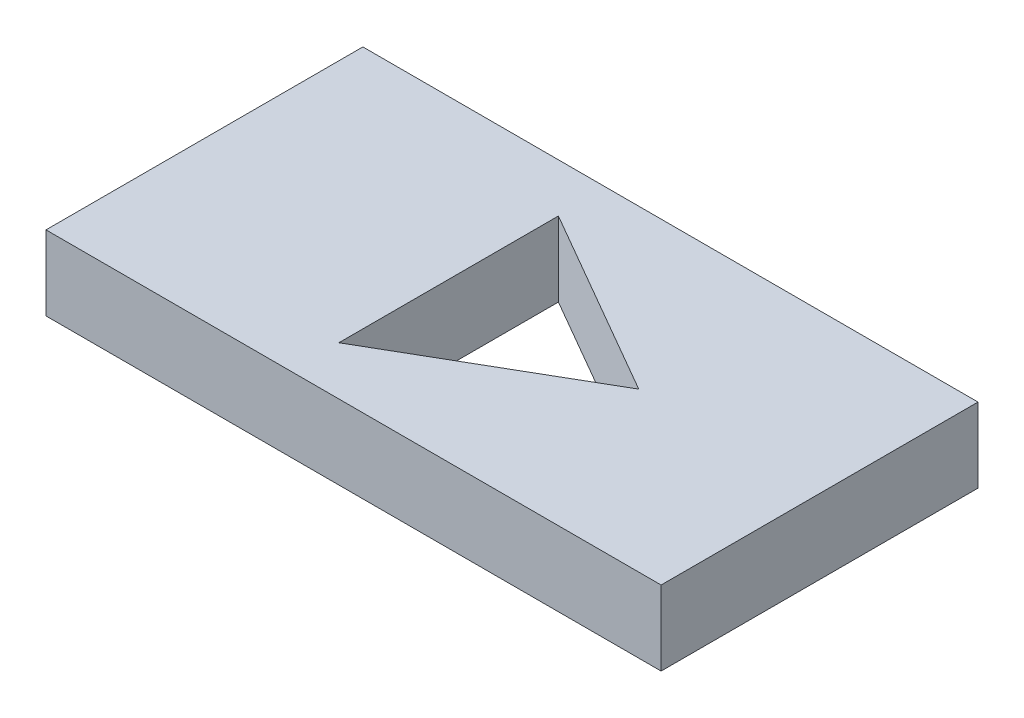
from build123d import *

# Parameters (mm, degrees)
SKETCH1_W           = 209.55
SKETCH1_H           = 107.95
BOSS_EXTRUDE1_DEPTH = 25.4


with BuildPart() as part:
    # Sketch1 → Boss-Extrude1 (new body)
    with BuildSketch(Plane(origin=(0, 0, 0), x_dir=(1, 0, 0), z_dir=(0, 1, 0))):
        Rectangle(SKETCH1_W, SKETCH1_H)
        Polygon((-21.59, 37.394976935), (-21.59, -37.394976935), (43.18, 0), align=None, mode=Mode.SUBTRACT)
    extrude(amount=BOSS_EXTRUDE1_DEPTH)


solid = part.part
